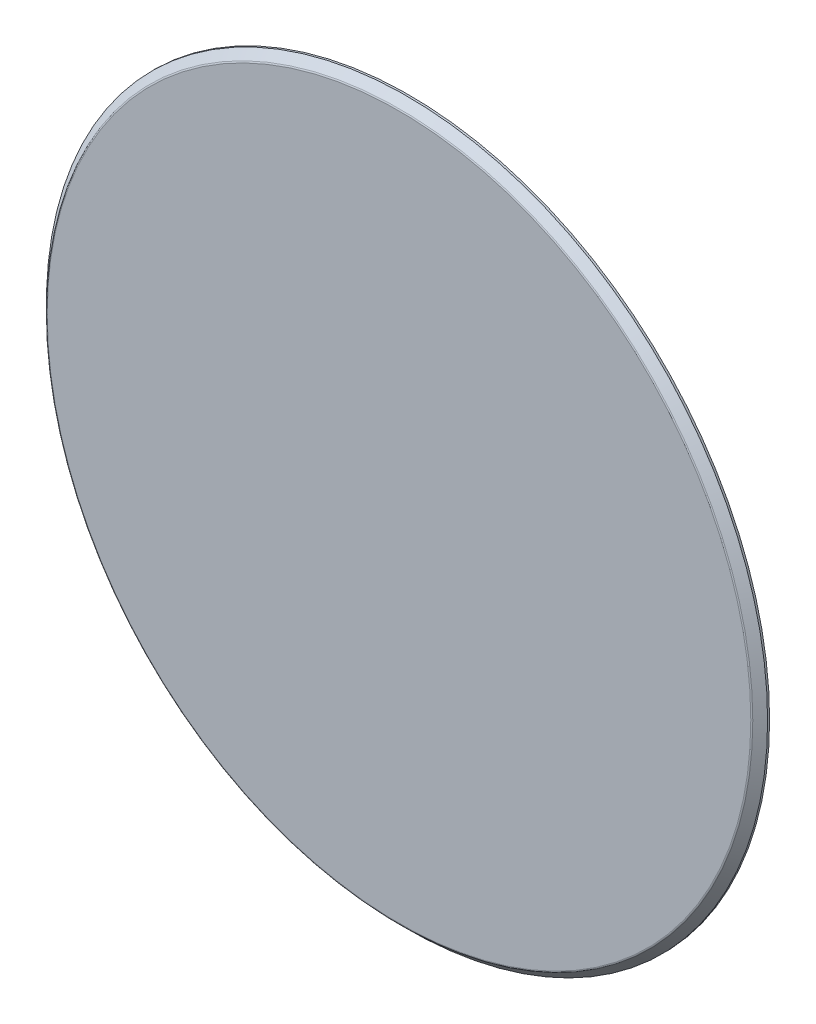
from build123d import *

# Parameters (mm, degrees)
SKETCH1_R           = 18.04750383
BOSS_EXTRUDE1_DEPTH = 0.5
CHAMFER1_SIZE       = 0.4
FILLET1_R           = 0.1


with BuildPart() as part:
    # Sketch1 → Boss-Extrude1 (new body)
    with BuildSketch(Plane.XY):
        with Locations((0, 20)):
            Circle(SKETCH1_R)
    extrude(amount=BOSS_EXTRUDE1_DEPTH)

    # Chamfer1
    chamfer1_edges = [part.edges().sort_by_distance(p)[0] for p in [
        (-18.04750383, 20, 0.5),
    ]]
    chamfer(chamfer1_edges, length=CHAMFER1_SIZE)

    # Fillet1
    fillet1_edges = [part.edges().sort_by_distance(p)[0] for p in [
        (-17.64750383, 20, 0.5),
    ]]
    fillet(fillet1_edges, radius=FILLET1_R)


solid = part.part
